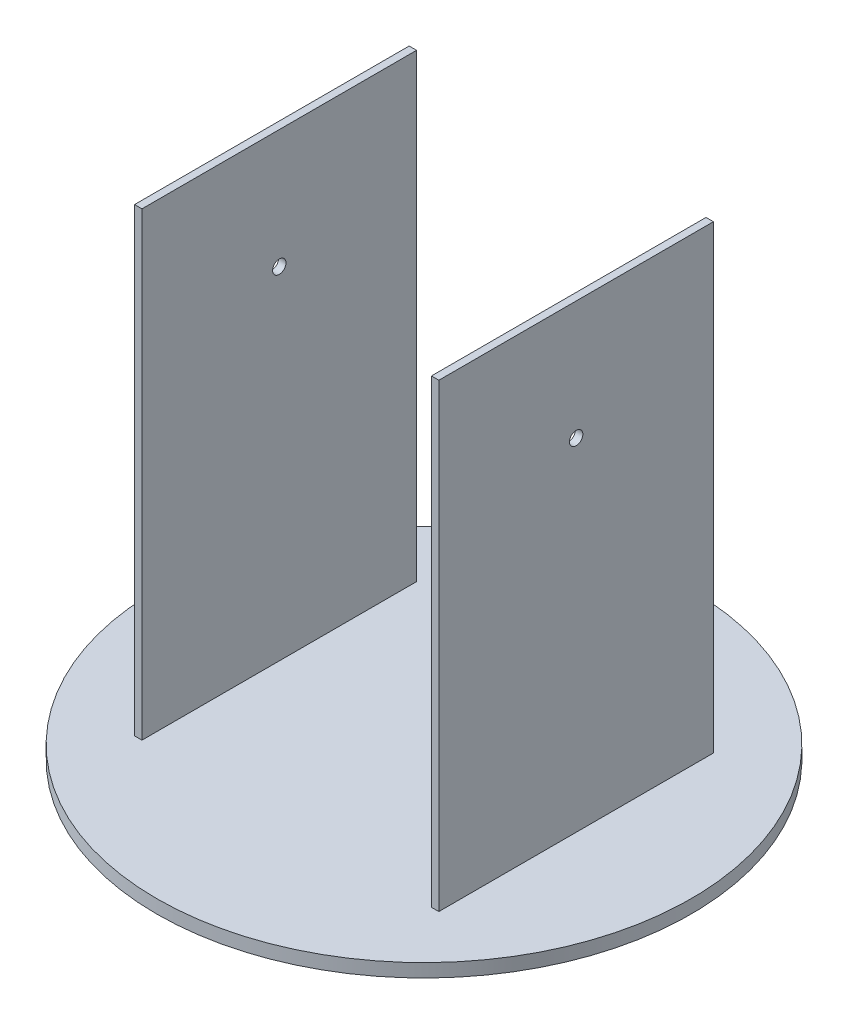
from build123d import *

# Parameters (mm, degrees)
SKETCH2_R               = 180
BOSS_EXTRUDE1_DEPTH     = 9
SKETCH3_W               = 5
SKETCH3_H               = 185
BOSS_EXTRUDE2_DEPTH     = 310
SKETCH7_R               = 4.5
CUT_EXTRUDE2_DEPTH      = 181
CUT_EXTRUDE2_DEPTH_BACK = 181


with BuildPart() as part:
    # Sketch2 → Boss-Extrude1 (new body)
    with BuildSketch(Plane(origin=(0, 0, 0), x_dir=(1, 0, 0), z_dir=(0, 1, 0))):
        Circle(SKETCH2_R)
    extrude(amount=-BOSS_EXTRUDE1_DEPTH)

    # Sketch3 → Boss-Extrude2 (add)
    with BuildSketch(Plane(origin=(0, 0, 0), x_dir=(1, 0, 0), z_dir=(0, 1, 0))):
        with Locations((-100, 0)):
            Rectangle(SKETCH3_W, SKETCH3_H)
        with Locations((100, 0)):
            Rectangle(SKETCH3_W, SKETCH3_H)
    extrude(amount=BOSS_EXTRUDE2_DEPTH)

    # Sketch7 → Cut-Extrude2 (cut, two sides)
    with BuildSketch(Plane(origin=(0, 0, 0), x_dir=(0, 0, -1), z_dir=(1, 0, 0))) as cut_extrude2_sk:
        with Locations((0, 230)):
            Circle(SKETCH7_R)
    extrude(amount=CUT_EXTRUDE2_DEPTH, mode=Mode.SUBTRACT)
    extrude(cut_extrude2_sk.sketch, amount=-CUT_EXTRUDE2_DEPTH_BACK, mode=Mode.SUBTRACT)


solid = part.part
